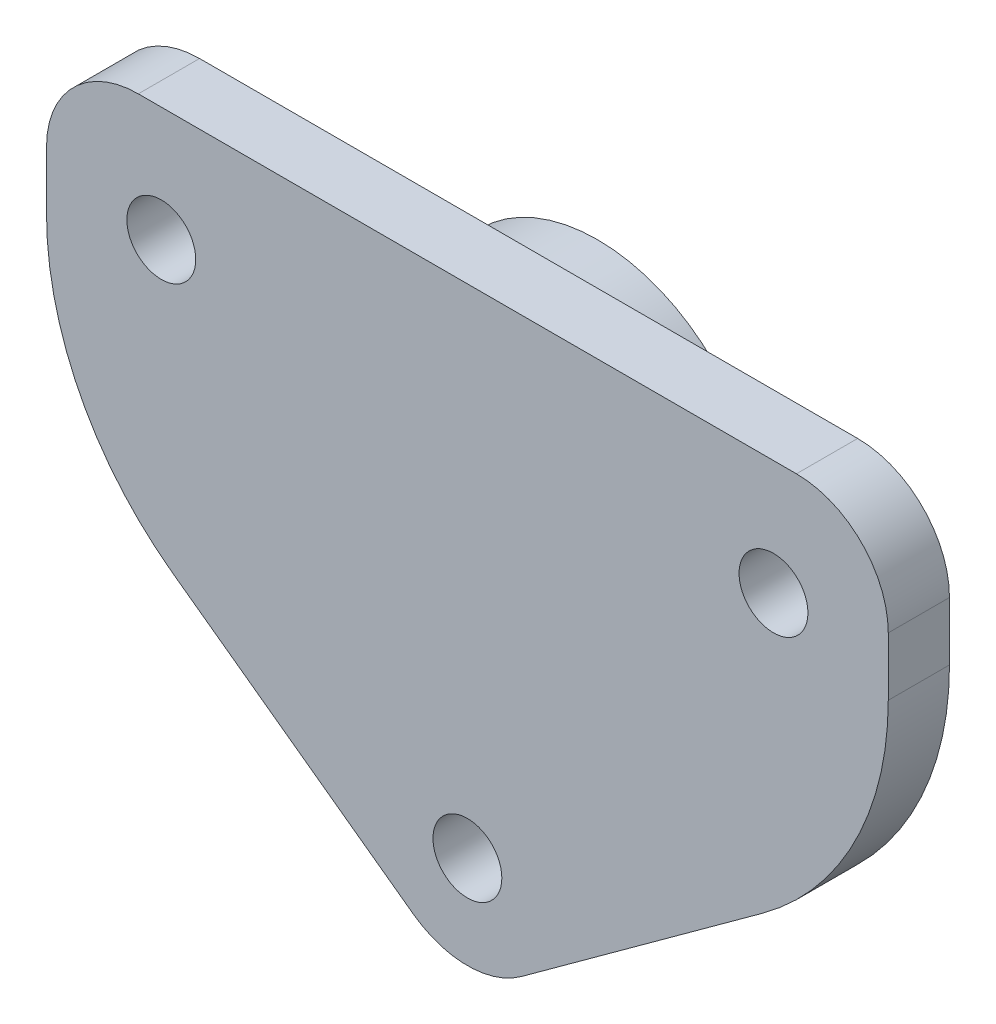
from build123d import *

# Parameters (mm, degrees)
ESQUISSE1_R        = 2.25
BOSS_EXTRU_1_DEPTH = 4
CONG_2_R           = 6
CONG_3_R           = 20
ESQUISSE2_R        = 10.75
BOSS_EXTRU_2_DEPTH = 4.5


with BuildPart() as part:
    # Esquisse1 → Boss.-Extru.1 (new body)
    with BuildSketch(Plane.XY):
        Polygon((-55, 20), (-27.5, 0), (0, 20), (0, 40), (-55, 40), align=None)
        with Locations((-47.5, 32.5)):
            Circle(ESQUISSE1_R, mode=Mode.SUBTRACT)
        with Locations((-7.5, 32.5)):
            Circle(ESQUISSE1_R, mode=Mode.SUBTRACT)
        with Locations((-27.5, 7.5)):
            Circle(ESQUISSE1_R, mode=Mode.SUBTRACT)
    extrude(amount=BOSS_EXTRU_1_DEPTH)

    # Congé2
    cong_2_edges = [part.edges().sort_by_distance(p)[0] for p in [
        (-55, 40, 2),
        (0, 40, 2),
        (-27.5, 0, 2),
    ]]
    fillet(cong_2_edges, radius=CONG_2_R)

    # Congé3
    cong_3_edges = [part.edges().sort_by_distance(p)[0] for p in [
        (0, 20, 2),
        (-55, 20, 2),
    ]]
    fillet(cong_3_edges, radius=CONG_3_R)

    # Esquisse2 → Boss.-Extru.2 (add)
    with BuildSketch(Plane(origin=(0, 0, 0), x_dir=(-1, 0, 0), z_dir=(0, 0, -1))):
        with Locations(Location((27.5, 27.5, 0), (0, 0, 180))):  # turned: the seam where the file's is
            Circle(ESQUISSE2_R)
    extrude(amount=BOSS_EXTRU_2_DEPTH)


solid = part.part
